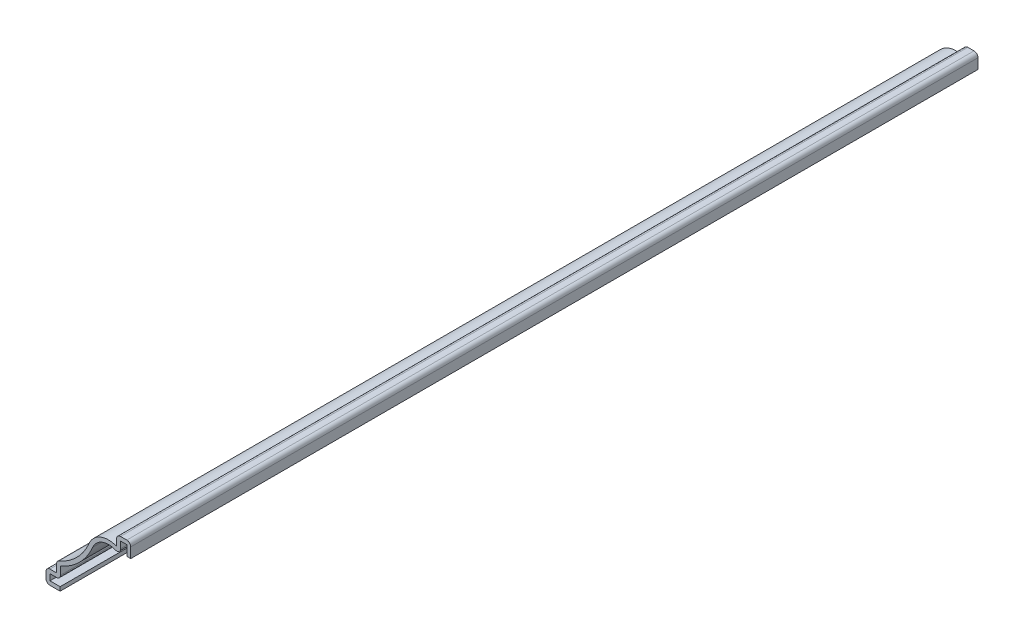
from build123d import *

# Parameters (mm, degrees)
EXTRUDE_THIN1_DEPTH = 190.5
FILLET1_R           = 0.889


with BuildPart() as part:
    # Sketch1 → Extrude-Thin1 (new body)
    with BuildSketch(Plane.XY):
        with BuildLine():
            Line((0, 14.2875), (0, 17.4625))
            Line((0, 17.4625), (-3.175, 17.4625))
            Line((-3.175, 17.4625), (-3.175, 15.08125))
            ThreePointArc((-3.175, 15.08125), (-6.80591832, 15.086090387), (-9.38501075, 12.530337363))
            ThreePointArc((-9.38501075, 12.530337363), (-12.305011444, 8.289373521), (-16.66875, 5.55625))
            Line((-16.66875, 5.55625), (-16.66875, 3.175))
            Line((-16.66875, 3.175), (-19.05, 3.175))
            Line((-19.05, 3.175), (-19.05, 0))
            Line((-19.05, 0), (-15.875, 0))
            Line((-15.875, 0), (-15.875, 0.889))
            Line((-15.875, 0.889), (-18.161, 0.889))
            Line((-18.161, 0.889), (-18.161, 2.286))
            Line((-18.161, 2.286), (-15.77975, 2.286))
            Line((-15.77975, 2.286), (-15.77975, 4.95323652))
            ThreePointArc((-15.77975, 4.95323652), (-11.467396752, 7.865532848), (-8.565790095, 12.185085979))
            ThreePointArc((-8.565790095, 12.185085979), (-5.760091082, 14.478232), (-2.286, 13.448107355))
            Line((-2.286, 13.448107355), (-2.286, 16.5735))
            Line((-2.286, 16.5735), (-0.889, 16.5735))
            Line((-0.889, 16.5735), (-0.889, 14.2875))
            Line((-0.889, 14.2875), (0, 14.2875))
        make_face()
    extrude(amount=-EXTRUDE_THIN1_DEPTH)

    # Fillet1
    fillet1_edges = [part.edges().sort_by_distance(p)[0] for p in [
        (-19.05, 0, -95.25),
        (-19.05, 3.175, -95.25),
        (-16.66875, 5.55625, -95.25),
        (-3.175, 17.4625, -95.25),
        (0, 17.4625, -95.25),
        (-2.286, 13.448107355, -95.25),
        (-15.77975, 2.286, -95.25),
    ]]
    fillet(fillet1_edges, radius=FILLET1_R)


solid = part.part
